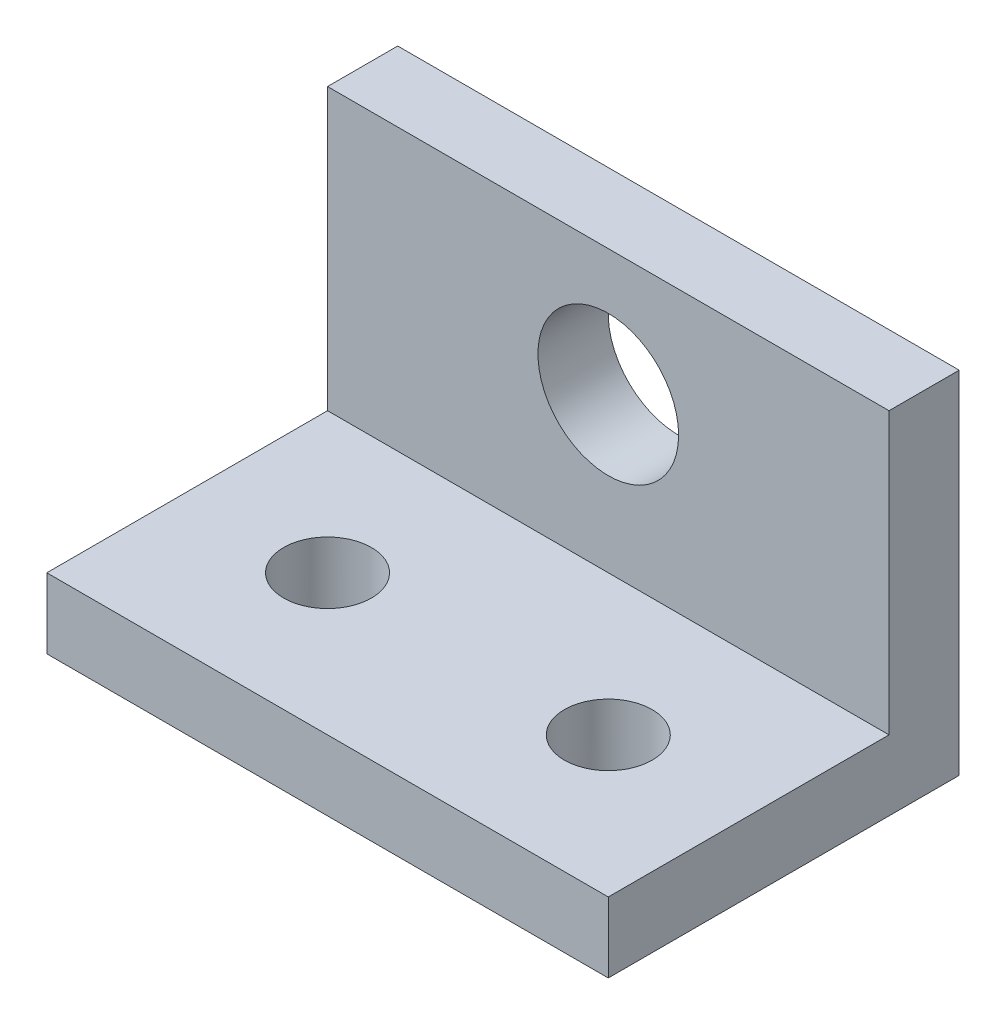
from build123d import *

# Parameters (mm, degrees)
SKETCH1_W           = 25.4
SKETCH1_H           = 6.35
SKETCH1_W_2         = 6.35
SKETCH1_H_2         = 31.75
BOSS_EXTRUDE1_DEPTH = 50.8
CUT_EXTRUDE1_REACH  = 8.35
SKETCH2_R           = 6.3627
CUT_EXTRUDE2_REACH  = 8.35
SKETCH3_R           = 3.96875


with BuildPart() as part:
    # Sketch1 → Boss-Extrude1 (new body)
    with BuildSketch(Plane(origin=(0, 0, 0), x_dir=(0, 0, -1), z_dir=(1, 0, 0))):
        with Locations((-19.05, 3.175)):
            Rectangle(SKETCH1_W, SKETCH1_H)
        with Locations((-3.175, 15.875)):
            Rectangle(SKETCH1_W_2, SKETCH1_H_2)
    extrude(amount=BOSS_EXTRUDE1_DEPTH)

    # Sketch2 → Cut-Extrude1 (cut, up to next)
    with BuildSketch(Plane.XY.offset(6.35), mode=Mode.PRIVATE) as cut_extrude1_sk1:
        with Locations((25.4, 20.32)):
            Circle(SKETCH2_R)
    cut_extrude1_tool1 = extrude(cut_extrude1_sk1.sketch, amount=-CUT_EXTRUDE1_REACH, mode=Mode.PRIVATE) & part.part
    add(cut_extrude1_tool1.solids().sort_by_distance((25.4, 20.32, 6.35))[0], mode=Mode.SUBTRACT)

    # Sketch3 → Cut-Extrude2 (cut, up to next)
    with BuildSketch(Plane(origin=(0, 6.35, 0), x_dir=(1, 0, 0), z_dir=(0, 1, 0)), mode=Mode.PRIVATE) as cut_extrude2_sk1:
        with Locations((12.7, -19.05)):
            Circle(SKETCH3_R)
    cut_extrude2_tool1 = extrude(cut_extrude2_sk1.sketch, amount=-CUT_EXTRUDE2_REACH, mode=Mode.PRIVATE) & part.part
    add(cut_extrude2_tool1.solids().sort_by_distance((12.7, 6.35, 19.05))[0], mode=Mode.SUBTRACT)
    # Sketch3 → Cut-Extrude2 (cut, up to next)
    with BuildSketch(Plane(origin=(0, 6.35, 0), x_dir=(1, 0, 0), z_dir=(0, 1, 0)), mode=Mode.PRIVATE) as cut_extrude2_sk2:
        with Locations((38.1, -19.05)):
            Circle(SKETCH3_R)
    cut_extrude2_tool2 = extrude(cut_extrude2_sk2.sketch, amount=-CUT_EXTRUDE2_REACH, mode=Mode.PRIVATE) & part.part
    add(cut_extrude2_tool2.solids().sort_by_distance((38.1, 6.35, 19.05))[0], mode=Mode.SUBTRACT)


solid = part.part
